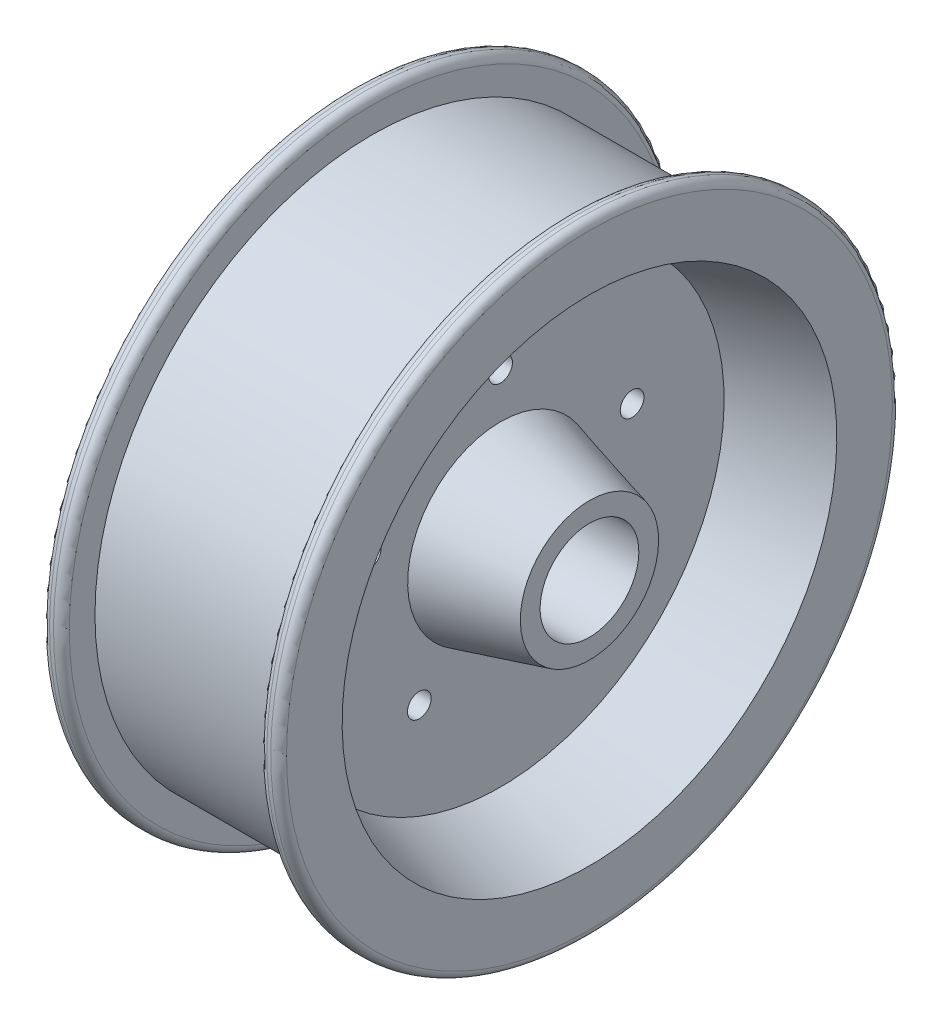
from build123d import *

# Parameters (mm, degrees)
SKETCH3_R          = 3.81
CUT_EXTRUDE1_DEPTH = 19.05
CIRPATTERN1_COUNT  = 5


with BuildPart() as part:
    # Sketch1 → Revolve2 (revolve)
    with BuildSketch(Plane.XY):
        with BuildLine():
            Line((0, 110.13359097), (0, 36.858618068))
            Line((0, 36.858618068), (38.1, 36.858618068))
            Line((38.1, 36.858618068), (38.1, 43.208618068))
            Line((38.1, 43.208618068), (9.525, 50.865266242))
            Line((9.525, 50.865266242), (9.525, 92.854369894))
            Line((9.525, 92.854369894), (38.1, 100.511018068))
            Line((38.1, 100.511018068), (38.1, 118.38859097))
            ThreePointArc((38.1, 118.38859097), (37.356051224, 120.184642194), (35.56, 120.92859097))
            Line((35.56, 120.92859097), (34.29, 120.92859097))
            ThreePointArc((34.29, 120.92859097), (32.493948776, 120.184642194), (31.75, 118.38859097))
            Line((31.75, 118.38859097), (31.75, 110.13359097))
            Line((31.75, 110.13359097), (0, 110.13359097))
        make_face()
        with BuildLine():
            Line((-38.1, 43.208618068), (-38.1, 36.858618068))
            Line((-38.1, 36.858618068), (0, 36.858618068))
            Line((0, 36.858618068), (0, 110.13359097))
            Line((0, 110.13359097), (-31.75, 110.13359097))
            Line((-31.75, 110.13359097), (-31.75, 118.38859097))
            ThreePointArc((-31.75, 118.38859097), (-32.493948776, 120.184642194), (-34.29, 120.92859097))
            Line((-34.29, 120.92859097), (-35.56, 120.92859097))
            ThreePointArc((-35.56, 120.92859097), (-37.356051224, 120.184642194), (-38.1, 118.38859097))
            Line((-38.1, 118.38859097), (-38.1, 100.511018068))
            Line((-38.1, 100.511018068), (-9.525, 92.854369894))
            Line((-9.525, 92.854369894), (-9.525, 50.865266242))
            Line((-9.525, 50.865266242), (-38.1, 43.208618068))
        make_face()
    revolve(axis=Axis((104.96947807, 20.983618068, 0), (-1, 0, 0)))

    # Sketch3 → Cut-Extrude1 (cut)
    with BuildSketch(Plane(origin=(9.525, 0, 0), x_dir=(0, 0, -1), z_dir=(1, 0, 0))):
        with Locations((0, 65.433618068)):
            Circle(SKETCH3_R)
    cut_extrude1 = extrude(amount=-CUT_EXTRUDE1_DEPTH, mode=Mode.SUBTRACT)

    # CirPattern1: Cut-Extrude1 ×5 about axis
    cirpattern1_axis = Axis((0, 20.983618068, 0), (1, 0, 0))
    for i in range(1, CIRPATTERN1_COUNT):
        add(cut_extrude1.rotate(cirpattern1_axis, i * 360 / CIRPATTERN1_COUNT), mode=Mode.SUBTRACT)


solid = part.part
